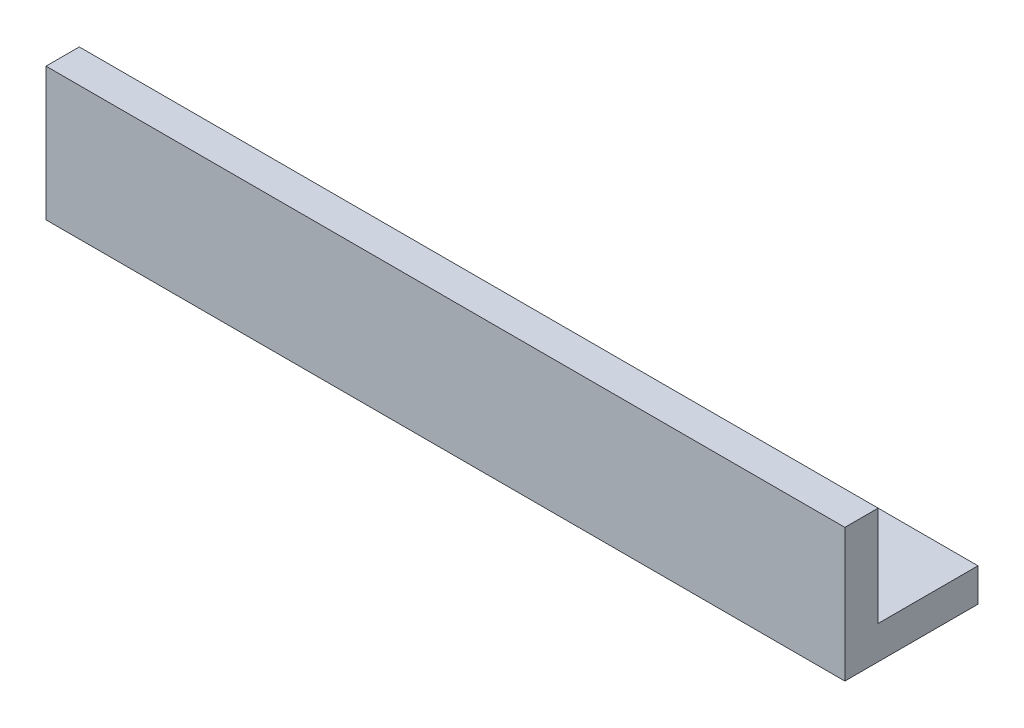
from build123d import *

# Parameters (mm, degrees)
SKETCH1_W           = 76.2
SKETCH1_H           = 12.7
BOSS_EXTRUDE1_DEPTH = 3.175
SKETCH7_W           = 76.2
SKETCH7_H           = 9.525
BOSS_EXTRUDE2_DEPTH = 3.175


with BuildPart() as part:
    # Sketch1 → Boss-Extrude1 (new body)
    with BuildSketch(Plane.XY):
        with Locations((33.686472643, 22.354273404)):
            Rectangle(SKETCH1_W, SKETCH1_H)
    extrude(amount=BOSS_EXTRUDE1_DEPTH)

    # Sketch7 → Boss-Extrude2 (add)
    with BuildSketch(Plane(origin=(0, 16.004273404, 0), x_dir=(-1, 0, 0), z_dir=(0, -1, 0))):
        with Locations((-33.686472643, 4.7625)):
            Rectangle(SKETCH7_W, SKETCH7_H)
    extrude(amount=-BOSS_EXTRUDE2_DEPTH)


solid = part.part
